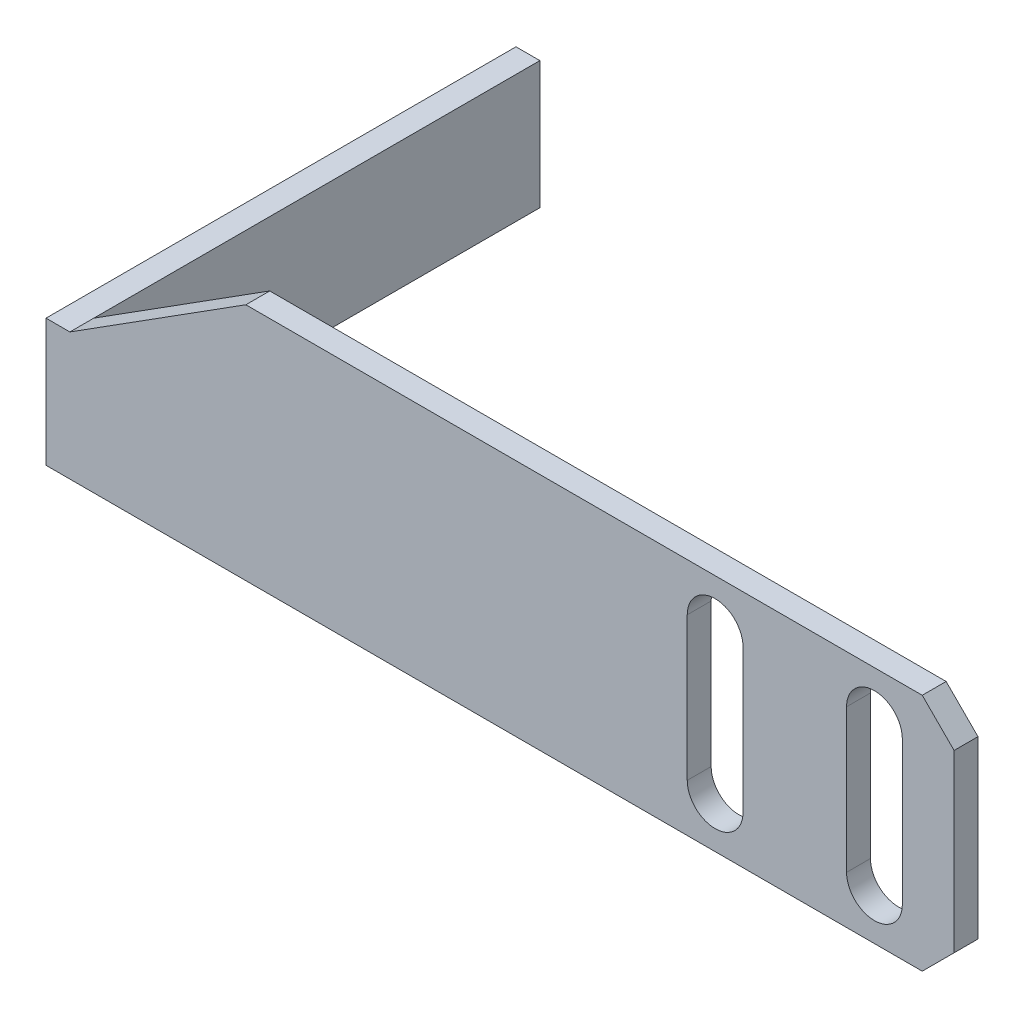
from build123d import *

# Parameters (mm, degrees)
BOSS_EXTRUDE2_DEPTH = 1.5
SKETCH5_W           = 1.5
SKETCH5_H           = 8
BOSS_EXTRUDE3_DEPTH = 28
CUT_EXTRUDE1_DEPTH  = 28
CHAMFER1_SIZE       = 2


with BuildPart() as part:
    # Sketch4 → Boss-Extrude2 (new body)
    with BuildSketch(Plane.XY):
        Polygon((-21.818181818, -18.75), (35.181818182, -18.75), (35.181818182, -3.75), (-9.272727273, -3.75), (-20.318181818, -10.75), (-21.818181818, -10.75), align=None)
    extrude(amount=BOSS_EXTRUDE2_DEPTH)

    # Sketch5 → Boss-Extrude3 (add)
    with BuildSketch(Plane(origin=(0, 0, 0), x_dir=(-1, 0, 0), z_dir=(0, 0, -1))):
        with Locations((21.068181818, -14.75)):
            Rectangle(SKETCH5_W, SKETCH5_H)
    extrude(amount=BOSS_EXTRUDE3_DEPTH)

    # Sketch6 → Cut-Extrude1 (cut)
    with BuildSketch(Plane.XY.offset(1.5)):
        with BuildLine():
            Line((18.431818182, -6.75), (18.431818182, -15.75))
            ThreePointArc((18.431818182, -15.75), (20.181818182, -17.5), (21.931818182, -15.75))
            Line((21.931818182, -15.75), (21.931818182, -6.75))
            ThreePointArc((21.931818182, -6.75), (20.181818182, -5), (18.431818182, -6.75))
        make_face()
        with BuildLine():
            Line((28.431818182, -6.75), (28.431818182, -15.75))
            ThreePointArc((28.431818182, -15.75), (30.181818182, -17.5), (31.931818182, -15.75))
            Line((31.931818182, -15.75), (31.931818182, -6.75))
            ThreePointArc((31.931818182, -6.75), (30.181818182, -5), (28.431818182, -6.75))
        make_face()
    extrude(amount=-CUT_EXTRUDE1_DEPTH, mode=Mode.SUBTRACT)

    # Chamfer1
    chamfer1_edges = [part.edges().sort_by_distance(p)[0] for p in [
        (35.181818182, -3.75, 0.75),
        (35.181818182, -18.75, 0.75),
    ]]
    chamfer(chamfer1_edges, length=CHAMFER1_SIZE)


solid = part.part
